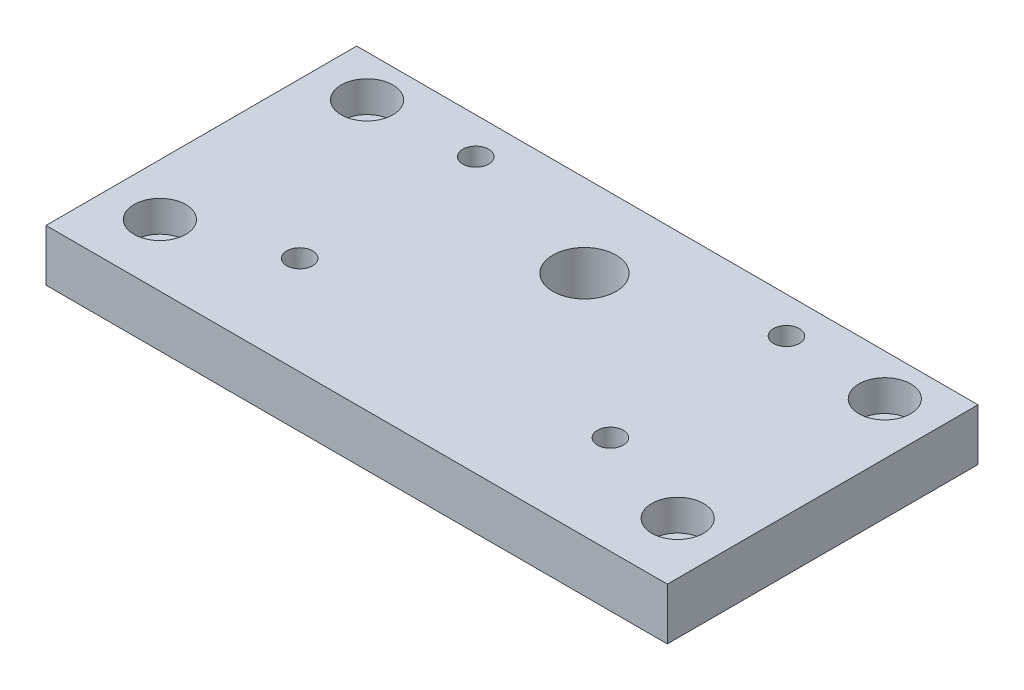
from build123d import *

# Parameters (mm, degrees)
SKETCH1_W           = 60
SKETCH1_H           = 30
BOSS_EXTRUDE1_DEPTH = 5
SKETCH2_R           = 3.05
SKETCH2_R_2         = 1.25
CUT_EXTRUDE1_DEPTH  = 5
SKETCH3_R           = 1.25
CUT_EXTRUDE2_DEPTH  = 5
SKETCH4_R           = 2.5
CUT_EXTRUDE3_DEPTH  = 3


with BuildPart() as part:
    # Sketch1 → Boss-Extrude1 (new body)
    with BuildSketch(Plane(origin=(0, 0, 0), x_dir=(1, 0, 0), z_dir=(0, 1, 0))):
        with Locations((30, 15)):
            Rectangle(SKETCH1_W, SKETCH1_H)
    extrude(amount=BOSS_EXTRUDE1_DEPTH)

    # Sketch2 → Cut-Extrude1 (cut)
    with BuildSketch(Plane(origin=(0, 5, 0), x_dir=(1, 0, 0), z_dir=(0, 1, 0))):
        with Locations((30, 22)):
            Circle(SKETCH2_R)
        with Locations((45, 26.5)):
            Circle(SKETCH2_R_2)
        with Locations((45, 9.5)):
            Circle(SKETCH2_R_2)
    cut_extrude1 = extrude(amount=-CUT_EXTRUDE1_DEPTH, mode=Mode.SUBTRACT)

    # Mirror1: Cut-Extrude1 across plane
    add(cut_extrude1.mirror(Plane.ZY.offset(-30)), mode=Mode.SUBTRACT)

    # Sketch3 → Cut-Extrude2 (cut)
    with BuildSketch(Plane(origin=(0, 5, 0), x_dir=(1, 0, 0), z_dir=(0, 1, 0))):
        with Locations((55, 26)):
            Circle(SKETCH3_R)
        with Locations((55, 6)):
            Circle(SKETCH3_R)
    cut_extrude2 = extrude(amount=-CUT_EXTRUDE2_DEPTH, mode=Mode.SUBTRACT)

    # Mirror2: Cut-Extrude2 across plane
    add(cut_extrude2.mirror(Plane.ZY.offset(-30)), mode=Mode.SUBTRACT)

    # Sketch4 → Cut-Extrude3 (cut)
    with BuildSketch(Plane(origin=(0, 5, 0), x_dir=(1, 0, 0), z_dir=(0, 1, 0))):
        with Locations((55, 26)):
            Circle(SKETCH4_R)
        with Locations((55, 6)):
            Circle(SKETCH4_R)
    cut_extrude3 = extrude(amount=-CUT_EXTRUDE3_DEPTH, mode=Mode.SUBTRACT)

    # Mirror3: Cut-Extrude3 across plane
    add(cut_extrude3.mirror(Plane.ZY.offset(-30)), mode=Mode.SUBTRACT)


solid = part.part
